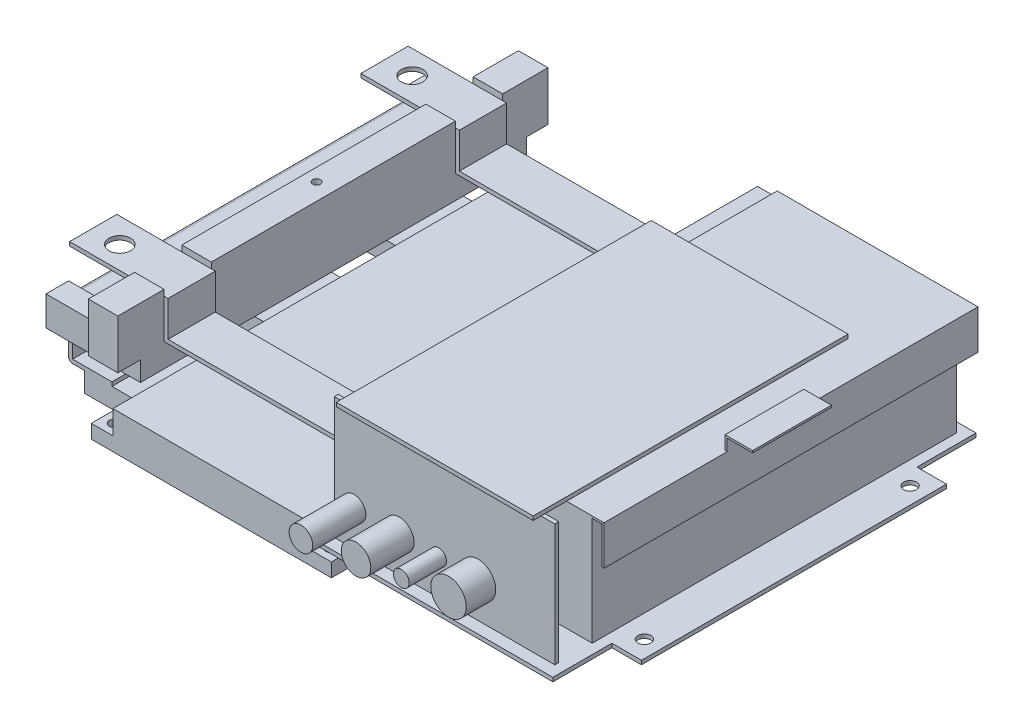
from build123d import *

# Parameters (mm, degrees)
SZKIC1_W                                = 122
SZKIC1_H                                = 62
DODANIE_WYCI_GNI_CIE1_DEPTH             = 7
DODANIE_WYCI_GNI_CIE1_2_DEPTH           = 7
DODANIE_WYCI_GNI_CIE1_3_DEPTH           = 7
SZKIC2_W                                = 100
SZKIC2_H                                = 62
DODANIE_WYCI_GNI_CIE2_DEPTH             = 10
SZKIC3_W                                = 100
SZKIC3_H                                = 196
DODANIE_WYCI_GNI_CIE3_DEPTH             = 2
OTW_R_POD_RUB_M51_D                     = 5.5
OTW_R_POD_RUB_M51_DEPTH                 = 14
OTW_R_POD_RUB_M51_TIP                   = 1.652366702
SZKIC6_W                                = 15
SZKIC6_H                                = 39
SZKIC6_W_2                              = 11
DODANIE_WYCI_GNI_CIE4_DEPTH             = 10
DODANIE_WYCI_GNI_CIE5_REACH             = 202.443
ZAOKR_GLENIE1_R                         = 2
OTW_R_GWINTOWANY_M101_D                 = 8.5
OTW_R_GWINTOWANY_M101_DEPTH             = 2
SZKIC11_W                               = 11.5
SZKIC11_H                               = 15
DODANIE_WYCI_GNI_CIE7_DEPTH             = 48
DODANIE_WYCI_GNI_CIE8_REACH             = 211.399
DODANIE_WYCI_GNI_CIE8_DIRECTION_2_REACH = 211.399
SZKIC13_W                               = 15
SZKIC13_H                               = 25
DODANIE_WYCI_GNI_CIE9_DEPTH             = 11.5
SZKIC14_W                               = 15
SZKIC14_H                               = 25
DODANIE_WYCI_GNI_CIE10_DEPTH            = 11
SZKIC15_W                               = 15
SZKIC15_H                               = 24
WYTNIJ_WYCI_GNI_CIE1_DEPTH              = 5
SZKIC16_W                               = 16
SZKIC16_H                               = 35
DODANIE_WYCI_GNI_CIE11_DEPTH            = 3
SZKIC17_W                               = 16
SZKIC17_H                               = 35
SZKIC17_W_2                             = 15
SZKIC17_H_2                             = 155
DODANIE_WYCI_GNI_CIE14_DEPTH            = 2
OTW_R_POD_RUB_M61_D                     = 6.6
SZKIC20_R                               = 5
WYTNIJ_WYCI_GNI_CIE2_DEPTH              = 8
SZKIC21_W                               = 95
SZKIC21_H                               = 185
DODANIE_WYCI_GNI_CIE15_DEPTH            = 55
DODANIE_WYCI_GNI_CIE16_DEPTH            = 24
SZKIC24_W                               = 5.5
SZKIC24_H                               = 32
OTW_R_POD_RUB_M101_AT_2_COUNT           = 2
OTW_R_POD_RUB_M101_AT_2_PITCH           = 148.5
DODANIE_WYCI_GNI_CIE17_DEPTH            = 190
SZKIC26_W                               = 112
SZKIC26_H                               = 2
DODANIE_WYCI_GNI_CIE18_DEPTH            = 62
SZKIC27_W                               = 100
SZKIC27_H                               = 160
DODANIE_WYCI_GNI_CIE19_DEPTH            = 2
SZKIC28_W                               = 9
SZKIC28_H                               = 55
DODANIE_WYCI_GNI_CIE20_DEPTH            = 9
DODANIE_WYCI_GNI_CIE21_DEPTH            = 20
OTWORY_USTALAJ_CE_4_0MM1_D              = 4
OTWORY_USTALAJ_CE_4_0MM1_DEPTH          = 35
SZKIC33_R                               = 6
DODANIE_WYCI_GNI_CIE22_DEPTH            = 27
SZKIC34_R                               = 7.5
DODANIE_WYCI_GNI_CIE23_DEPTH            = 22
SZKIC35_R                               = 4
DODANIE_WYCI_GNI_CIE24_DEPTH            = 19
SZKIC36_R                               = 9
DODANIE_WYCI_GNI_CIE25_DEPTH            = 15


with BuildPart() as part:
    # Szkic1 → Dodanie-wyciągnięcie1 (new body)
    with BuildSketch(Plane(origin=(0, 0, 0), x_dir=(1, 0, 0), z_dir=(0, 1, 0))):
        Rectangle(SZKIC1_W, SZKIC1_H)
    extrude(amount=DODANIE_WYCI_GNI_CIE1_DEPTH)



with BuildPart() as body_2:
    # Szkic1 → Dodanie-wyci_gni_cie1 2 (new body)
    with BuildSketch(Plane(origin=(0, 0, 0), x_dir=(1, 0, 0), z_dir=(0, 1, 0))):
        with Locations((0, 67)):
            Rectangle(SZKIC1_W, SZKIC1_H)
    extrude(amount=DODANIE_WYCI_GNI_CIE1_2_DEPTH)


with BuildPart() as body_3:
    # Szkic1 → Dodanie-wyci_gni_cie1 3 (new body)
    with BuildSketch(Plane(origin=(0, 0, 0), x_dir=(1, 0, 0), z_dir=(0, 1, 0))):
        with Locations((0, -67)):
            Rectangle(SZKIC1_W, SZKIC1_H)
    extrude(amount=DODANIE_WYCI_GNI_CIE1_3_DEPTH)


with BuildPart() as part_1:
    add(part.part)

    add(body_2.part)  # Dodanie-wyciągnięcie2 merges body 2

    add(body_3.part)  # Dodanie-wyciągnięcie2 merges body 3
    # Szkic2 → Dodanie-wyciągnięcie2 (add)
    with BuildSketch(Plane(origin=(0, 7, 0), x_dir=(1, 0, 0), z_dir=(0, 1, 0))):
        with Locations((0, -67)):
            Rectangle(SZKIC2_W, SZKIC2_H)
        Rectangle(SZKIC2_W, SZKIC2_H)
        with Locations((0, 67)):
            Rectangle(SZKIC2_W, SZKIC2_H)
    extrude(amount=DODANIE_WYCI_GNI_CIE2_DEPTH)

    # Szkic3 → Dodanie-wyciągnięcie3 (add)
    with BuildSketch(Plane(origin=(0, 17, 0), x_dir=(1, 0, 0), z_dir=(0, 1, 0))):
        Rectangle(SZKIC3_W, SZKIC3_H)
    extrude(amount=DODANIE_WYCI_GNI_CIE3_DEPTH)

    # Otwór pod śrubę M51
    with Locations(Plane(origin=(55, 0, 92), x_dir=(0, 0, -1), z_dir=(0, -1, 0))):
        with Locations((0, 0), (50, 0), (67, 0), (117, 0), (134, 0), (184, 0), (184, -110), (134, -110), (117, -110), (67, -110), (50, -110), (0, -110)):
            Hole(OTW_R_POD_RUB_M51_D / 2, depth=OTW_R_POD_RUB_M51_DEPTH)
            with Locations((0, 0, -(OTW_R_POD_RUB_M51_DEPTH + OTW_R_POD_RUB_M51_TIP / 2))):  # 118° drill point
                Cone(0, OTW_R_POD_RUB_M51_D / 2, OTW_R_POD_RUB_M51_TIP, mode=Mode.SUBTRACT)

    # Szkic6 → Dodanie-wyciągnięcie4 (add)
    with BuildSketch(Plane(origin=(0, 7, 0), x_dir=(1, 0, 0), z_dir=(0, 1, 0))):
        with Locations((-68.5, -67)):
            Rectangle(SZKIC6_W, SZKIC6_H)
        with Locations((-55.5, -67)):
            Rectangle(SZKIC6_W_2, SZKIC6_H)
        with Locations((-68.5, 0)):
            Rectangle(SZKIC6_W, SZKIC6_H)
        with Locations((-55.5, 0)):
            Rectangle(SZKIC6_W_2, SZKIC6_H)
        with Locations((-55.5, 67)):
            Rectangle(SZKIC6_W_2, SZKIC6_H)
        with Locations((-68.5, 67)):
            Rectangle(SZKIC6_W, SZKIC6_H)
        with Locations((55.5, 67)):
            Rectangle(SZKIC6_W_2, SZKIC6_H)
        with Locations((68.5, 67)):
            Rectangle(SZKIC6_W, SZKIC6_H)
        with Locations((55.5, 0)):
            Rectangle(SZKIC6_W_2, SZKIC6_H)
        with Locations((68.5, 0)):
            Rectangle(SZKIC6_W, SZKIC6_H)
        with Locations((55.5, -67)):
            Rectangle(SZKIC6_W_2, SZKIC6_H)
        with Locations((68.5, -67)):
            Rectangle(SZKIC6_W, SZKIC6_H)
    extrude(amount=DODANIE_WYCI_GNI_CIE4_DEPTH)

    # Dodanie-wyciągnięcie5: up to this face of the body (flat: up to its plane)
    dodanie_wyci_gni_cie5_end = Plane(part_1.part.faces().sort_by_distance((-63, 12, -86.5))[0])
    # Szkic7 → Dodanie-wyciągnięcie5 (add, up to the picked face)
    with BuildSketch(Plane.XY.offset(86.5), mode=Mode.PRIVATE) as dodanie_wyci_gni_cie5_sk1:
        Polygon((-62, 17), (-62, 19), (-82, 19), (-82, 45.454742832), (-51, 45.454742832), (-51, 47.454742832), (-84, 47.454742832), (-84, 17), align=None)
    dodanie_wyci_gni_cie5_tool1 = split(extrude(dodanie_wyci_gni_cie5_sk1.sketch, amount=-DODANIE_WYCI_GNI_CIE5_REACH, mode=Mode.PRIVATE), bisect_by=dodanie_wyci_gni_cie5_end, keep=Keep.BOTH, mode=Mode.PRIVATE)
    add(dodanie_wyci_gni_cie5_tool1.solids().sort_by(Axis((-62.449054, 18, 86.5), (0, 0, -1)))[0])

    # Zaokrąglenie1
    zaokr_glenie1_edges = [part_1.edges().sort_by_distance(p)[0] for p in [
        (-84, 17, 0),
        (-84, 47.454742832, 0),
    ]]
    fillet(zaokr_glenie1_edges, radius=ZAOKR_GLENIE1_R)

    # Otwór gwintowany M101
    with Locations(Plane(origin=(-69, 47.454742832, -37), x_dir=(1, 0, 0), z_dir=(0, 1, 0))):
        with Locations((0, 0), (0, -37), (0, -74)):
            Hole(OTW_R_GWINTOWANY_M101_D / 2, depth=OTW_R_GWINTOWANY_M101_DEPTH)

    # Szkic11 → Dodanie-wyciągnięcie7 (add)
    with BuildSketch(Plane.ZY.offset(84)):
        with Locations((92.25, 44.954742832)):
            Rectangle(SZKIC11_W, SZKIC11_H)
        with Locations((-92.25, 44.954742832)):
            Rectangle(SZKIC11_W, SZKIC11_H)
    extrude(amount=-DODANIE_WYCI_GNI_CIE7_DEPTH)

    # Dodanie-wyciągnięcie8: up to this face of the body (flat: up to its plane)
    dodanie_wyci_gni_cie8_end = Plane(part_1.part.faces().sort_by_distance((-60, 44.954742832, -98))[0])
    # Szkic12 → Dodanie-wyciągnięcie8 (add, up to the picked face)
    with BuildSketch(Plane(origin=(0, 0, 86.5), x_dir=(-1, 0, 0), z_dir=(0, 0, -1)), mode=Mode.PRIVATE) as dodanie_wyci_gni_cie8_sk1:
        Polygon((82, 45.454742832), (82, 37.454742832), (36, 37.454742832), (36, 72.454742832), (51, 72.454742832), (51, 45.454742832), align=None)
    dodanie_wyci_gni_cie8_tool1 = split(extrude(dodanie_wyci_gni_cie8_sk1.sketch, amount=DODANIE_WYCI_GNI_CIE8_REACH, mode=Mode.PRIVATE), bisect_by=dodanie_wyci_gni_cie8_end, keep=Keep.BOTH, mode=Mode.PRIVATE)
    add(dodanie_wyci_gni_cie8_tool1.solids().sort_by(Axis((-50.879043, 50.623566, 86.5), (0, 0, -1)))[0])

    # Dodanie-wyciągnięcie8 direction 2: up to this face of the body (flat: up to its plane)
    dodanie_wyci_gni_cie8_direction_2_end = Plane(part_1.part.faces().sort_by_distance((-60, 44.954742832, 98))[0])
    # Szkic12 → Dodanie-wyciągnięcie8 direction 2 (add, up to the picked face)
    with BuildSketch(Plane(origin=(0, 0, 86.5), x_dir=(-1, 0, 0), z_dir=(0, 0, -1)), mode=Mode.PRIVATE) as dodanie_wyci_gni_cie8_direction_2_sk1:
        Polygon((82, 45.454742832), (82, 37.454742832), (36, 37.454742832), (36, 72.454742832), (51, 72.454742832), (51, 45.454742832), align=None)
    dodanie_wyci_gni_cie8_direction_2_tool1 = split(extrude(dodanie_wyci_gni_cie8_direction_2_sk1.sketch, amount=-DODANIE_WYCI_GNI_CIE8_DIRECTION_2_REACH, mode=Mode.PRIVATE), bisect_by=dodanie_wyci_gni_cie8_direction_2_end, keep=Keep.BOTH, mode=Mode.PRIVATE)
    add(dodanie_wyci_gni_cie8_direction_2_tool1.solids().sort_by(Axis((-50.879043, 50.623566, 86.5), (0, 0, 1)))[0])

    # Szkic13 → Dodanie-wyciągnięcie9 (add)
    with BuildSketch(Plane.XY.offset(98)):
        with Locations((-43.5, 59.954742832)):
            Rectangle(SZKIC13_W, SZKIC13_H)
    extrude(amount=DODANIE_WYCI_GNI_CIE9_DEPTH)

    # Szkic14 → Dodanie-wyciągnięcie10 (add)
    with BuildSketch(Plane(origin=(0, 0, -98), x_dir=(-1, 0, 0), z_dir=(0, 0, -1))):
        with Locations((43.5, 59.954742832)):
            Rectangle(SZKIC14_W, SZKIC14_H)
    extrude(amount=DODANIE_WYCI_GNI_CIE10_DEPTH)

    # Szkic15 → Wytnij-wyciągnięcie1 (cut)
    with BuildSketch(Plane(origin=(0, 72.454742832, 0), x_dir=(1, 0, 0), z_dir=(0, 1, 0))):
        with Locations((-43.5, 74)):
            Rectangle(SZKIC15_W, SZKIC15_H)
        with Locations((-43.5, -74)):
            Rectangle(SZKIC15_W, SZKIC15_H)
    extrude(amount=-WYTNIJ_WYCI_GNI_CIE1_DEPTH, mode=Mode.SUBTRACT)

    # Szkic16 → Dodanie-wyciągnięcie11 (add)
    with BuildSketch(Plane(origin=(0, 17, 0), x_dir=(1, 0, 0), z_dir=(0, 1, 0))):
        with Locations((68, -67)):
            Rectangle(SZKIC16_W, SZKIC16_H)
        with Locations((68, 0)):
            Rectangle(SZKIC16_W, SZKIC16_H)
        with Locations((68, 67)):
            Rectangle(SZKIC16_W, SZKIC16_H)
    extrude(amount=DODANIE_WYCI_GNI_CIE11_DEPTH)

    # Szkic17 → Dodanie-wyciągnięcie14 (add)
    with BuildSketch(Plane(origin=(0, 20, 0), x_dir=(1, 0, 0), z_dir=(0, 1, 0))):
        Polygon((183, 107.5), (60, 107.5), (60, -49.5), (76, -49.5), (76, -84.5), (60, -84.5), (60, -107.5), (183, -107.5), (183, -77.5), (183, 77.5), align=None)
        with Locations((68, -67)):
            Rectangle(SZKIC17_W, SZKIC17_H)
        with Locations((190.5, 0)):
            Rectangle(SZKIC17_W_2, SZKIC17_H_2)
    extrude(amount=DODANIE_WYCI_GNI_CIE14_DEPTH)

    # Otwór pod śrubę M61 (through all)
    with Locations(Plane(origin=(189.5, 22, -67.5), x_dir=(0, 0, 1), z_dir=(0, 1, 0))):
        with Locations((0, 0), (135, 0)):
            Hole(OTW_R_POD_RUB_M61_D / 2)

    # Szkic20 → Wytnij-wyciągnięcie2 (cut)
    with BuildSketch(Plane(origin=(0, 45.454742832, 0), x_dir=(1, 0, 0), z_dir=(0, 1, 0))):
        with Locations(Location((-69, 37, 0), (0, 0, 180))):
            Circle(SZKIC20_R)
        with Locations(Location((-69, 0, 0), (0, 0, 180))):
            Circle(SZKIC20_R)
        with Locations(Location((-69, -37, 0), (0, 0, 180))):
            Circle(SZKIC20_R)
    extrude(amount=-WYTNIJ_WYCI_GNI_CIE2_DEPTH, mode=Mode.SUBTRACT)



with BuildPart() as body_2_2:
    # Szkic21 → Dodanie-wyciągnięcie15 (new body)
    with BuildSketch(Plane(origin=(0, 22, 0), x_dir=(1, 0, 0), z_dir=(0, 1, 0))):
        with Locations((130.5, 10)):
            Rectangle(SZKIC21_W, SZKIC21_H)
    extrude(amount=DODANIE_WYCI_GNI_CIE15_DEPTH)


with BuildPart() as body_3_2:
    # Szkic22 → Dodanie-wyciągnięcie16 (new body)
    with BuildSketch(Plane.XY.offset(62)):
        Polygon((-51, 67.454742832), (-84, 67.454742832), (-84, 69.454742832), (-34, 69.454742832), (-34, 51.454742832), (56, 51.454742832), (56, 27), (76, 27), (76, 25), (54, 25), (54, 49.454742832), (-36, 49.454742832), (-36, 67.454742832), align=None)
    extrude(amount=DODANIE_WYCI_GNI_CIE16_DEPTH)


with BuildPart() as body_4:
    # Lustro3: mirrored copy
    add(body_3_2.part.mirror(Plane.XY))

    # Szkic24 → Otwór pod śrubę M101 (revolve, cut)
    with BuildSketch(Plane(origin=(-70, 69.454742832, -74), x_dir=(0, 0, 1), z_dir=(1, 0, 0))):
        with Locations((2.75, 16)):
            Rectangle(SZKIC24_W, SZKIC24_H)
    otw_r_pod_rub_m101 = revolve(axis=Axis((-70, 75.804742832, -74), (0, -1, 0)), mode=Mode.SUBTRACT)


with BuildPart() as body_3_2_1:
    add(body_3_2.part)

    # Otwór pod śrubę M101 at 2: Otwór pod śrubę M101 ×2
    with Locations(*[(0, 0, i * OTW_R_POD_RUB_M101_AT_2_PITCH) for i in range(1, OTW_R_POD_RUB_M101_AT_2_COUNT)]):
        add(otw_r_pod_rub_m101, mode=Mode.SUBTRACT)


with BuildPart() as part_2:
    add(part_1.part)

    add(body_2_2.part)  # Dodanie-wyciągnięcie17 merges body 2 2

    add(body_3_2_1.part)  # Dodanie-wyciągnięcie17 merges body 3 2

    add(body_4.part)  # Dodanie-wyciągnięcie17 merges body 4
    # Szkic25 → Dodanie-wyciągnięcie17 (add)
    with BuildSketch(Plane.XY.offset(82.5)):
        Polygon((74, 74), (83, 74), (83, 77), (183, 77), (183, 58), (184, 58), (184, 78), (82, 78), (82, 75), (72, 75), (72, 74), align=None)
    extrude(amount=-DODANIE_WYCI_GNI_CIE17_DEPTH)

    # Szkic26 → Dodanie-wyciągnięcie18 (add)
    with BuildSketch(Plane(origin=(0, 22, 0), x_dir=(1, 0, 0), z_dir=(0, 1, 0))):
        with Locations((122, -100.5)):
            Rectangle(SZKIC26_W, SZKIC26_H)
    extrude(amount=DODANIE_WYCI_GNI_CIE18_DEPTH)

    # Szkic27 → Dodanie-wyciągnięcie19 (add)
    with BuildSketch(Plane(origin=(0, 84, 0), x_dir=(1, 0, 0), z_dir=(0, 1, 0))):
        with Locations((121, -25.5)):
            Rectangle(SZKIC27_W, SZKIC27_H)
    extrude(amount=DODANIE_WYCI_GNI_CIE19_DEPTH)

    # Szkic28 → Dodanie-wyciągnięcie20 (add)
    with BuildSketch(Plane(origin=(0, 84, 0), x_dir=(-1, 0, 0), z_dir=(0, -1, 0))):
        with Locations((-75.5, 27)):
            Rectangle(SZKIC28_W, SZKIC28_H)
    extrude(amount=DODANIE_WYCI_GNI_CIE20_DEPTH)

    # Szkic29 → Dodanie-wyciągnięcie21 (add, symmetric)
    with BuildSketch(Plane.XY):
        Polygon((183, 85), (197, 85), (197, 84), (184, 84), (184, 78), (183, 78), align=None)
    extrude(amount=DODANIE_WYCI_GNI_CIE21_DEPTH, both=True)

    # Otwory ustalające Ø4.0mm1
    with Locations(Plane(origin=(-44.5, 72.454742832, 0), x_dir=(0, 0, 1), z_dir=(0, 1, 0))):
        with Locations((0, 0)):
            Hole(OTWORY_USTALAJ_CE_4_0MM1_D / 2, depth=OTWORY_USTALAJ_CE_4_0MM1_DEPTH)

    # Szkic33 → Dodanie-wyciągnięcie22 (add)
    with BuildSketch(Plane.XY.offset(101.5)):
        with Locations(Location((76, 40, 0), (0, 0, 180))):
            Circle(SZKIC33_R)
    extrude(amount=DODANIE_WYCI_GNI_CIE22_DEPTH)

    # Szkic34 → Dodanie-wyciągnięcie23 (add)
    with BuildSketch(Plane.XY.offset(101.5)):
        with Locations(Location((99, 40, 0), (0, 0, 180))):
            Circle(SZKIC34_R)
    extrude(amount=DODANIE_WYCI_GNI_CIE23_DEPTH)

    # Szkic35 → Dodanie-wyciągnięcie24 (add)
    with BuildSketch(Plane.XY.offset(101.5)):
        with Locations(Location((119, 40, 0), (0, 0, 180))):
            Circle(SZKIC35_R)
    extrude(amount=DODANIE_WYCI_GNI_CIE24_DEPTH)

    # Szkic36 → Dodanie-wyciągnięcie25 (add)
    with BuildSketch(Plane.XY.offset(101.5)):
        with Locations(Location((139, 40, 0), (0, 0, 180))):
            Circle(SZKIC36_R)
    extrude(amount=DODANIE_WYCI_GNI_CIE25_DEPTH)


solid = part_2.part
